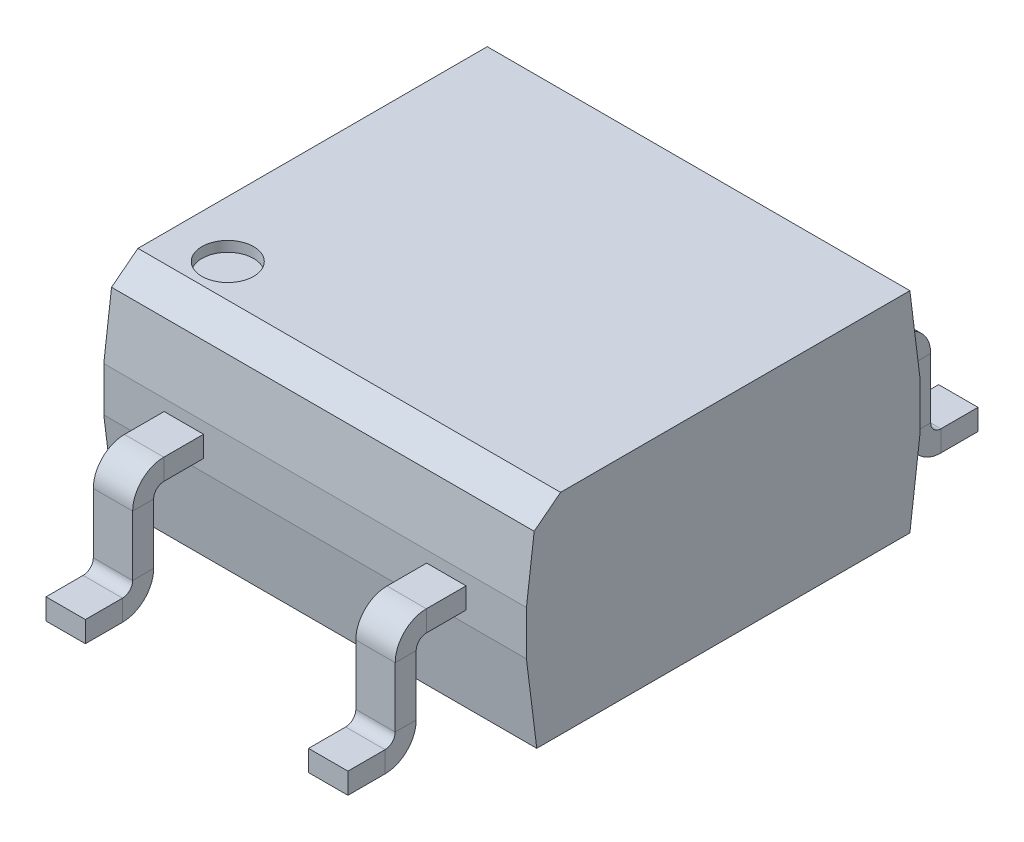
from build123d import *

# Parameters (mm, degrees)
SKETCH_1_W             = 4.089
SKETCH_1_H             = 3.81
EXTRUDE_1_DEPTH        = 2.03
CHAMFER_1_SIZE         = 0.8
CHAMFER_1_SIZE2        = 0.1
CHAMFER_1_PART_2_SIZE  = 0.8
CHAMFER_1_PART_2_SIZE2 = 0.1
CHAMFER_2_SIZE         = 0.1
CHAMFER_2_SIZE2        = 0.8
CHAMFER_3_SIZE2        = 0.2
CHAMFER_3_SIZE         = 0.230350221
SKETCH_2_R             = 0.25
CUT_EXTRUDE_1_DEPTH    = 0.1
SKETCH_3_W             = 0.381
SKETCH_3_H             = 0.203


with BuildPart() as part:
    # Эскиз1 → Бобышка-Вытянуть1 (new body)
    with BuildSketch(Plane(origin=(0, 0.064, 0), x_dir=(1, 0, 0), z_dir=(0, 1, 0))):
        Rectangle(SKETCH_1_W, SKETCH_1_H)
    extrude(amount=EXTRUDE_1_DEPTH)

    # Фаска1
    chamfer_1_edges = [part.edges().sort_by_distance(p)[0] for p in [
        (0, 2.094, 1.905),
    ]]
    chamfer_1_side = [part.faces().sort_by_distance(p)[0] for p in [
        (0, 1.079, 1.905),
    ]]
    chamfer(chamfer_1_edges, length=CHAMFER_1_SIZE, length2=CHAMFER_1_SIZE2, reference=chamfer_1_side[0])

    # Фаска1 part 2
    chamfer_1_part_2_edges = [part.edges().sort_by_distance(p)[0] for p in [
        (0, 2.094, -1.905),
    ]]
    chamfer_1_part_2_side = [part.faces().sort_by_distance(p)[0] for p in [
        (0, 1.079, -1.905),
    ]]
    chamfer(chamfer_1_part_2_edges, length=CHAMFER_1_PART_2_SIZE, length2=CHAMFER_1_PART_2_SIZE2, reference=chamfer_1_part_2_side[0])

    # Фаска2
    chamfer_2_edges = [part.edges().sort_by_distance(p)[0] for p in [
        (0, 0.064, 1.905),
        (0, 0.064, -1.905),
    ]]
    chamfer_2_side = [part.faces().sort_by_distance(p)[0] for p in [
        (0, 0.064, 0),
    ]]
    chamfer(chamfer_2_edges, length=CHAMFER_2_SIZE, length2=CHAMFER_2_SIZE2, reference=chamfer_2_side[0])

    # Фаска3
    chamfer_3_edges = [part.edges().sort_by_distance(p)[0] for p in [
        (0, 2.094, 1.805),
    ]]
    chamfer(chamfer_3_edges, length=CHAMFER_3_SIZE, length2=CHAMFER_3_SIZE2)

    # Эскиз2 → Вырез-Вытянуть1 (cut)
    with BuildSketch(Plane(origin=(0, 2.094, 0), x_dir=(1, 0, 0), z_dir=(0, 1, 0))):
        with Locations((-1.5, -1.25)):
            Circle(SKETCH_2_R)
    extrude(amount=-CUT_EXTRUDE_1_DEPTH, mode=Mode.SUBTRACT)

    # По траектории1: sweep along a path in Эскиз5
    with BuildLine(Plane(origin=(0, 0, 0), x_dir=(0, 0, -1), z_dir=(1, 0, 0))) as sweep_1_path:
        Line((-1.905, 1.0825), (-2.289, 1.0825))
        ThreePointArc((-2.289, 1.0825), (-2.430421356, 1.023921356), (-2.489, 0.8825))
        Line((-2.489, 0.8825), (-2.489, 0.3015))
        ThreePointArc((-2.489, 0.3015), (-2.547578644, 0.160078644), (-2.689, 0.1015))
        Line((-2.689, 0.1015), (-3.048, 0.1015))
    # Эскиз3 → По траектории1 (sweep)
    with BuildSketch(Plane.XY.offset(1.905)):
        with Locations((-1.27, 1.0825)):
            Rectangle(SKETCH_3_W, SKETCH_3_H)
        with Locations((1.27, 1.0825)):
            Rectangle(SKETCH_3_W, SKETCH_3_H)
    sweep_1 = sweep(path=sweep_1_path.line)

    # Зеркальное отражение1: По траектории1 across plane
    add(sweep_1.mirror(Plane.XY))


solid = part.part
